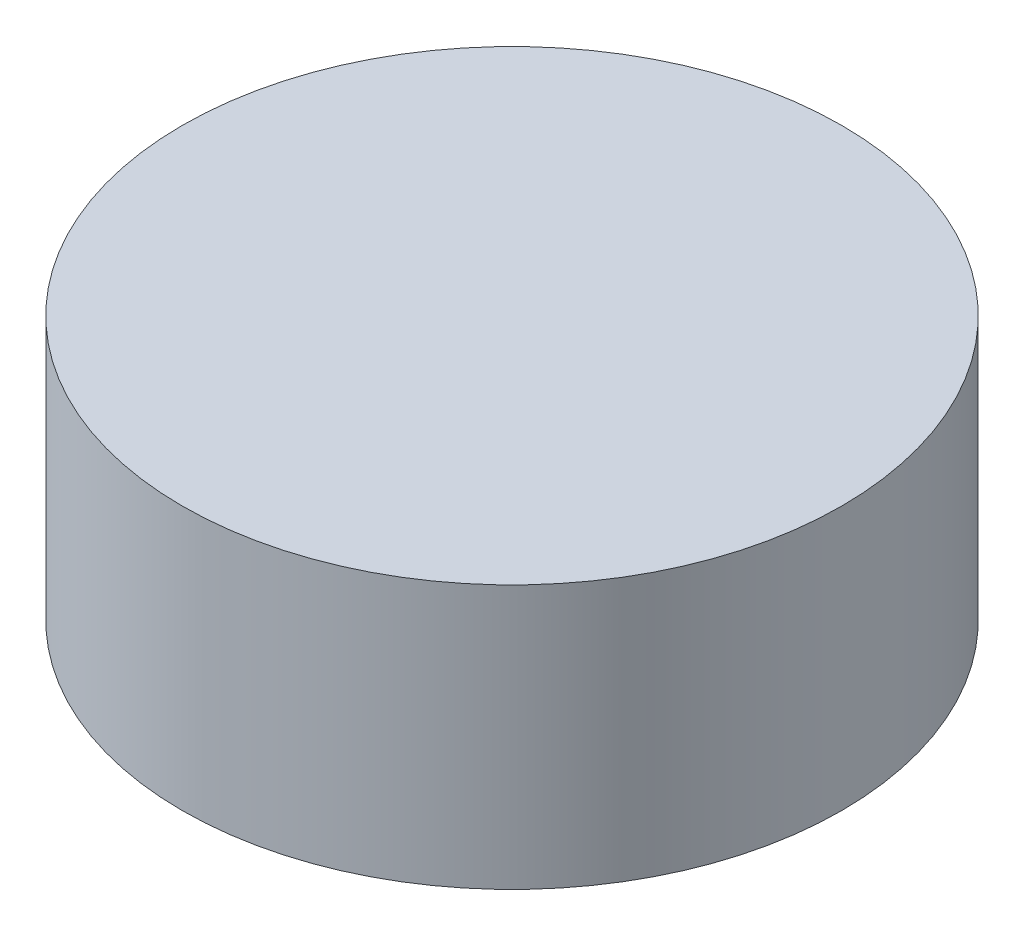
from build123d import *

# Parameters (mm, degrees)
SKETCH1_R           = 12.5
BOSS_EXTRUDE1_DEPTH = 10


with BuildPart() as part:
    # Sketch1 → Boss-Extrude1 (new body)
    with BuildSketch(Plane(origin=(0, 0, 0), x_dir=(1, 0, 0), z_dir=(0, 1, 0))):
        Circle(SKETCH1_R)
    extrude(amount=BOSS_EXTRUDE1_DEPTH)


solid = part.part
